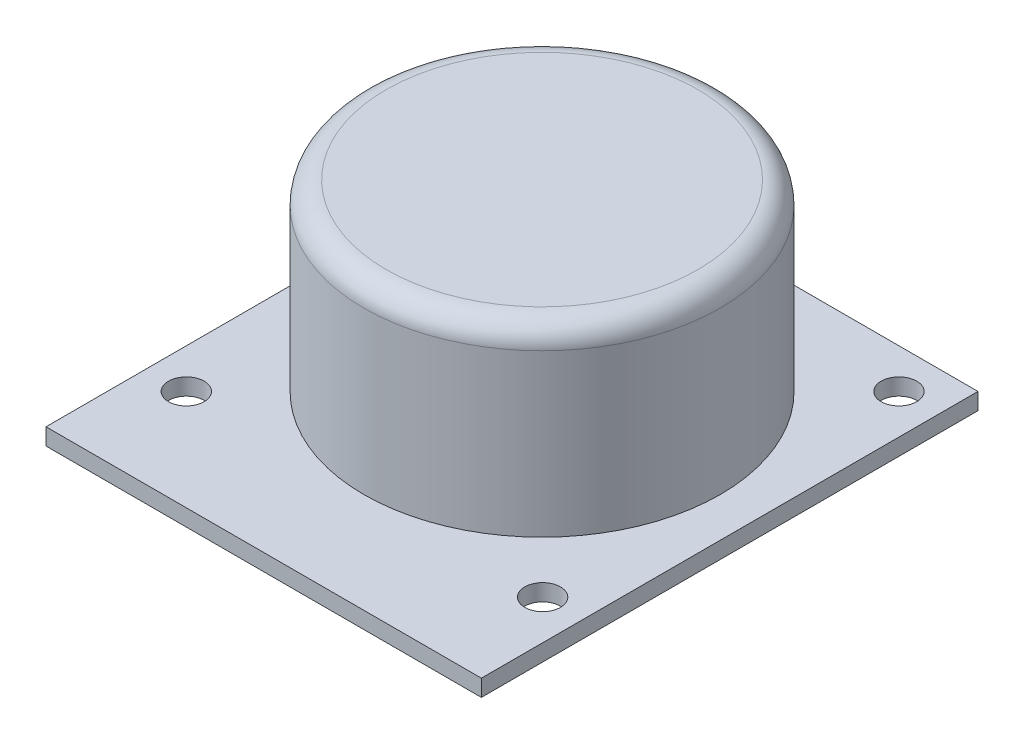
from build123d import *

# Parameters (mm, degrees)
SKETCH1_W           = 39.1
SKETCH1_H           = 44.6
BOSS_EXTRUDE1_DEPTH = 1.5
SKETCH2_R           = 1.6
CUT_EXTRUDE1_DEPTH  = 1.5
SKETCH3_R           = 16
BOSS_EXTRUDE2_DEPTH = 16.5
FILLET1_R           = 2


with BuildPart() as part:
    # Sketch1 → Boss-Extrude1 (new body)
    with BuildSketch(Plane(origin=(0, 0, 0), x_dir=(1, 0, 0), z_dir=(0, 1, 0))):
        with Locations((19.55, 22.3)):
            Rectangle(SKETCH1_W, SKETCH1_H)
    extrude(amount=BOSS_EXTRUDE1_DEPTH)

    # Sketch2 → Cut-Extrude1 (cut)
    with BuildSketch(Plane(origin=(0, 1.5, 0), x_dir=(1, 0, 0), z_dir=(0, 1, 0))):
        with Locations((35.55, 9.05)):
            Circle(SKETCH2_R)
        with Locations((35.55, 41.05)):
            Circle(SKETCH2_R)
        with Locations((3.55, 41.05)):
            Circle(SKETCH2_R)
        with Locations((3.55, 9.05)):
            Circle(SKETCH2_R)
    extrude(amount=-CUT_EXTRUDE1_DEPTH, mode=Mode.SUBTRACT)

    # Sketch3 → Boss-Extrude2 (add)
    with BuildSketch(Plane(origin=(0, 1.5, 0), x_dir=(1, 0, 0), z_dir=(0, 1, 0))):
        with Locations((19.55, 25)):
            Circle(SKETCH3_R)
    extrude(amount=BOSS_EXTRUDE2_DEPTH)

    # Fillet1
    fillet1_edges = [part.edges().sort_by_distance(p)[0] for p in [
        (3.55, 18, -25),
    ]]
    fillet(fillet1_edges, radius=FILLET1_R)


solid = part.part
